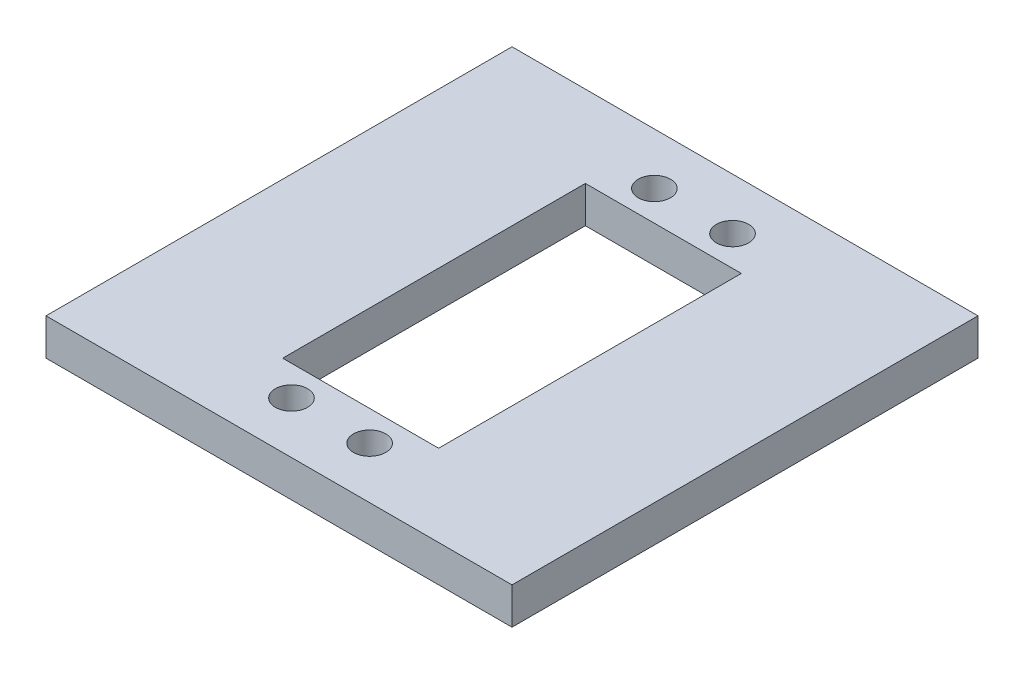
from build123d import *

# Parameters (mm, degrees)
SKETCH2_W           = 63.5
SKETCH2_H           = 63.5
BOSS_EXTRUDE1_DEPTH = 5
SKETCH3_R           = 2.2
SKETCH3_W           = 21.25
SKETCH3_H           = 41.25
CUT_EXTRUDE1_DEPTH  = 6


with BuildPart() as part:
    # Sketch2 → Boss-Extrude1 (new body)
    with BuildSketch(Plane(origin=(0, 0, 0), x_dir=(1, 0, 0), z_dir=(0, 1, 0))):
        Rectangle(SKETCH2_W, SKETCH2_H)
    extrude(amount=BOSS_EXTRUDE1_DEPTH)

    # Sketch3 → Cut-Extrude1 (cut, through all)
    with BuildSketch(Plane(origin=(0, 5, 0), x_dir=(1, 0, 0), z_dir=(0, 1, 0))):
        with Locations((5.325, 24.725)):
            Circle(SKETCH3_R)
        with Locations((-5.325, 24.725)):
            Circle(SKETCH3_R)
        with Locations((5.325, -24.725)):
            Circle(SKETCH3_R)
        with Locations((-5.325, -24.725)):
            Circle(SKETCH3_R)
        Rectangle(SKETCH3_W, SKETCH3_H)
    extrude(amount=-CUT_EXTRUDE1_DEPTH, mode=Mode.SUBTRACT)


solid = part.part
